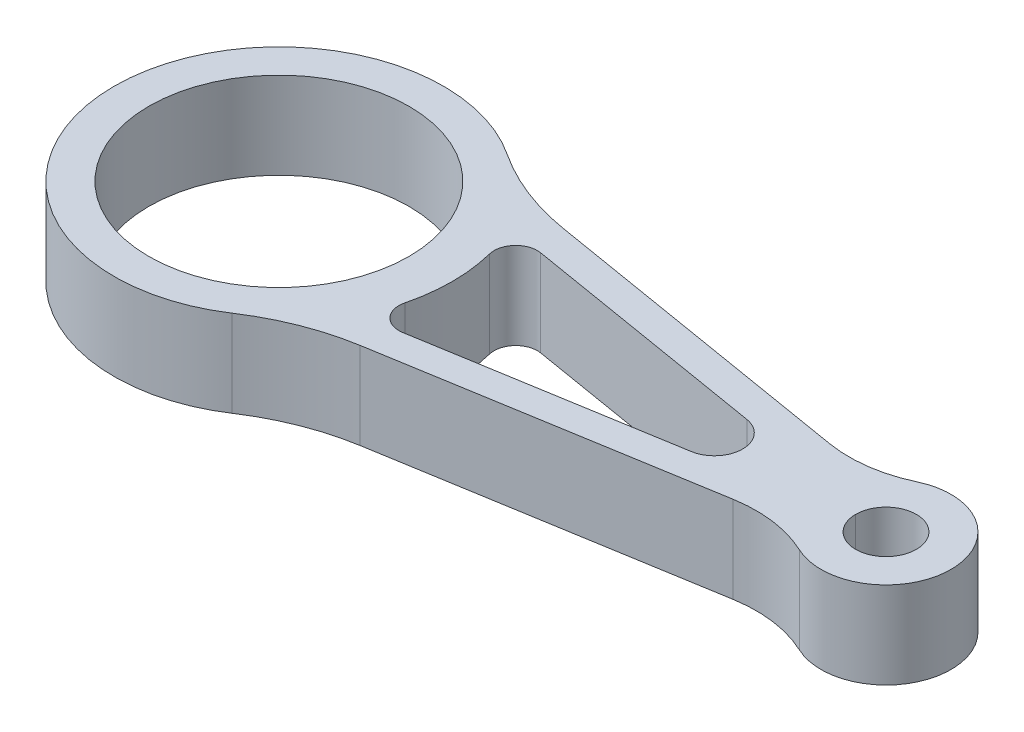
from build123d import *

# Parameters (mm, degrees)
SKETCH1_R           = 30
SKETCH1_R_2         = 7
BOSS_EXTRUDE1_DEPTH = 10
CUT_EXTRUDE1_DEPTH  = 21
FILLET1_R           = 30
FILLET2_R           = 55


with BuildPart() as part:
    # Sketch1 → Boss-Extrude1 (new body, symmetric)
    with BuildSketch(Plane(origin=(0, 0, 0), x_dir=(1, 0, 0), z_dir=(0, 1, 0))):
        with BuildLine():
            Line((128.063755469, 9.084385863), (27.935473676, 25.760615491))
            ThreePointArc((27.935473676, 25.760615491), (-38, 0), (27.935473676, -25.760615491))
            Line((27.935473676, -25.760615491), (128.063755469, -9.084385863))
            ThreePointArc((128.063755469, -9.084385863), (155, 0), (128.063755469, 9.084385863))
        make_face()
        Circle(SKETCH1_R, mode=Mode.SUBTRACT)
        with Locations((140, 0)):
            Circle(SKETCH1_R_2, mode=Mode.SUBTRACT)
    extrude(amount=BOSS_EXTRUDE1_DEPTH, both=True)

    # Sketch2 → Cut-Extrude1 (cut, through all)
    with BuildSketch(Plane(origin=(0, 10, 0), x_dir=(1, 0, 0), z_dir=(0, 1, 0))):
        with BuildLine():
            Line((44.461373165, 15.911828816), (101.502639752, 6.411683174))
            ThreePointArc((101.502639752, 6.411683174), (106.934782609, 0), (101.502639752, -6.411683174))
            Line((101.502639752, -6.411683174), (44.461373165, -15.911828816))
            ThreePointArc((44.461373165, -15.911828816), (39.963398771, -14.368423983), (38.791061861, -9.759790965))
            ThreePointArc((38.791061861, -9.759790965), (40, 0), (38.791061861, 9.759790965))
            ThreePointArc((38.791061861, 9.759790965), (39.963398771, 14.368423983), (44.461373165, 15.911828816))
        make_face()
    extrude(amount=-CUT_EXTRUDE1_DEPTH, mode=Mode.SUBTRACT)

    # Fillet1
    fillet1_edges = [part.edges().sort_by_distance(p)[0] for p in [
        (128.063755469, 0, 9.084385863),
        (128.063755469, 0, -9.084385863),
    ]]
    fillet(fillet1_edges, radius=FILLET1_R)

    # Fillet2
    fillet2_edges = [part.edges().sort_by_distance(p)[0] for p in [
        (27.935473676, 0, 25.760615491),
        (27.935473676, 0, -25.760615491),
    ]]
    fillet(fillet2_edges, radius=FILLET2_R)


solid = part.part
